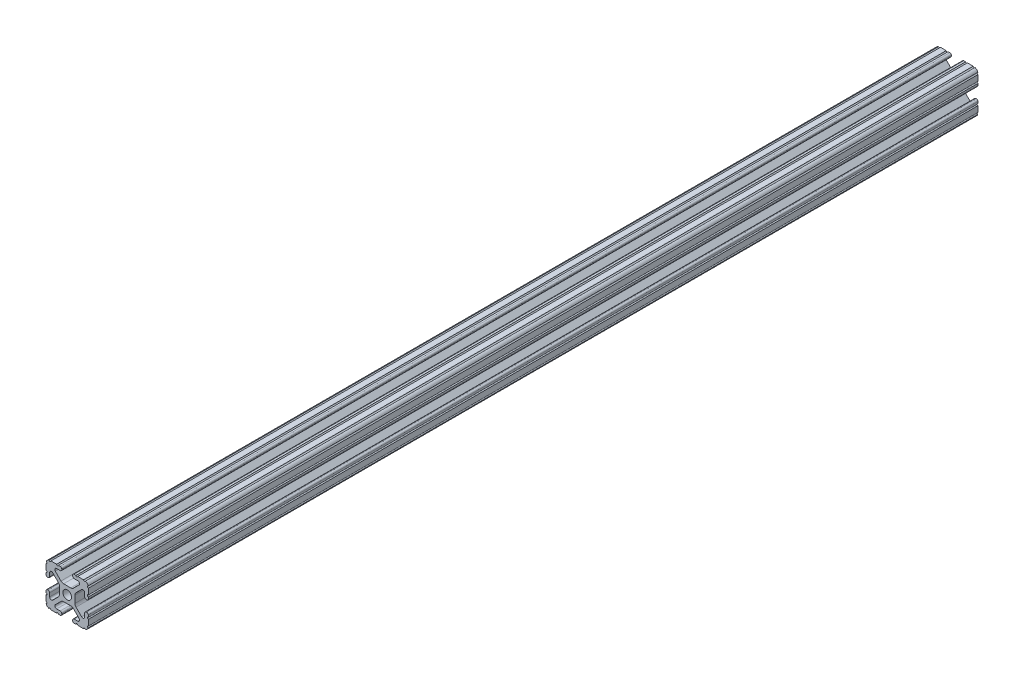
from build123d import *

# Parameters (mm, degrees)
BOSS_EXTRUDE1_DEPTH     = 266.6
SKETCH5_R               = 0.55245
CUT_EXTRUDE1_DEPTH      = 267.6
CUT_EXTRUDE1_DEPTH_BACK = 267.6


with BuildPart() as part:
    # Sketch4 → Boss-Extrude1 (new body, symmetric)
    with BuildSketch(Plane.XY):
        with BuildLine():
            Line((4.190365, -12.7), (10.11729625, -12.7))
            ThreePointArc((10.11729625, -12.7), (11.943543585, -11.943543585), (12.7, -10.11729625))
            Line((12.7, -10.11729625), (12.7, -4.190365))
            ThreePointArc((12.7, -4.190365), (12.42492494, -3.52627506), (11.760835, -3.2512))
            Line((11.760835, -3.2512), (11.429365, -3.2512))
            ThreePointArc((11.429365, -3.2512), (10.76527506, -3.52627506), (10.4902, -4.190365))
            Line((10.4902, -4.190365), (10.4902, -6.348478019))
            ThreePointArc((10.4902, -6.348478019), (9.830707141, -7.335478831), (8.666460301, -7.103895736))
            Line((8.666460301, -7.103895736), (5.299899128, -3.737334563))
            ThreePointArc((5.299899128, -3.737334563), (4.817571085, -3.015479634), (4.6482, -2.16399369))
            Line((4.6482, -2.16399369), (4.6482, 0))
            Line((4.6482, 0), (2.6035, 0))
            ThreePointArc((2.6035, 0), (1.840952505, -1.840952505), (0, -2.6035))
            Line((0, -2.6035), (0, -4.6482))
            Line((0, -4.6482), (2.16399369, -4.6482))
            ThreePointArc((2.16399369, -4.6482), (3.015479634, -4.817571085), (3.737334563, -5.299899128))
            Line((3.737334563, -5.299899128), (7.103895736, -8.666460301))
            ThreePointArc((7.103895736, -8.666460301), (7.335478831, -9.830707141), (6.348478019, -10.4902))
            Line((6.348478019, -10.4902), (4.190365, -10.4902))
            ThreePointArc((4.190365, -10.4902), (3.52627506, -10.76527506), (3.2512, -11.429365))
            Line((3.2512, -11.429365), (3.2512, -11.760835))
            ThreePointArc((3.2512, -11.760835), (3.52627506, -12.42492494), (4.190365, -12.7))
        make_face()
    extrude(amount=BOSS_EXTRUDE1_DEPTH, both=True)

    # Sketch5 → Cut-Extrude1 (cut, two sides)
    with BuildSketch(Plane.XY) as cut_extrude1_sk:
        with Locations((10.356153152, -12.7)):
            Circle(SKETCH5_R)
        with Locations((5.796028019, -12.7)):
            Circle(SKETCH5_R)
        with Locations((12.7, -10.356153152)):
            Circle(SKETCH5_R)
        with Locations((12.7, -5.796028019)):
            Circle(SKETCH5_R)
    extrude(amount=CUT_EXTRUDE1_DEPTH, mode=Mode.SUBTRACT)
    extrude(cut_extrude1_sk.sketch, amount=-CUT_EXTRUDE1_DEPTH_BACK, mode=Mode.SUBTRACT)

    # Mirror1: part across plane


with BuildPart() as part_1:
    add(part.part)
    add(part.part.mirror(Plane(origin=(0, 0, 0), x_dir=(0, 0, 1), z_dir=(1, 0, 0))))

    # Mirror2: part across plane


with BuildPart() as part_2:
    add(part_1.part)
    add(part_1.part.mirror(Plane.ZX))


solid = part_2.part
